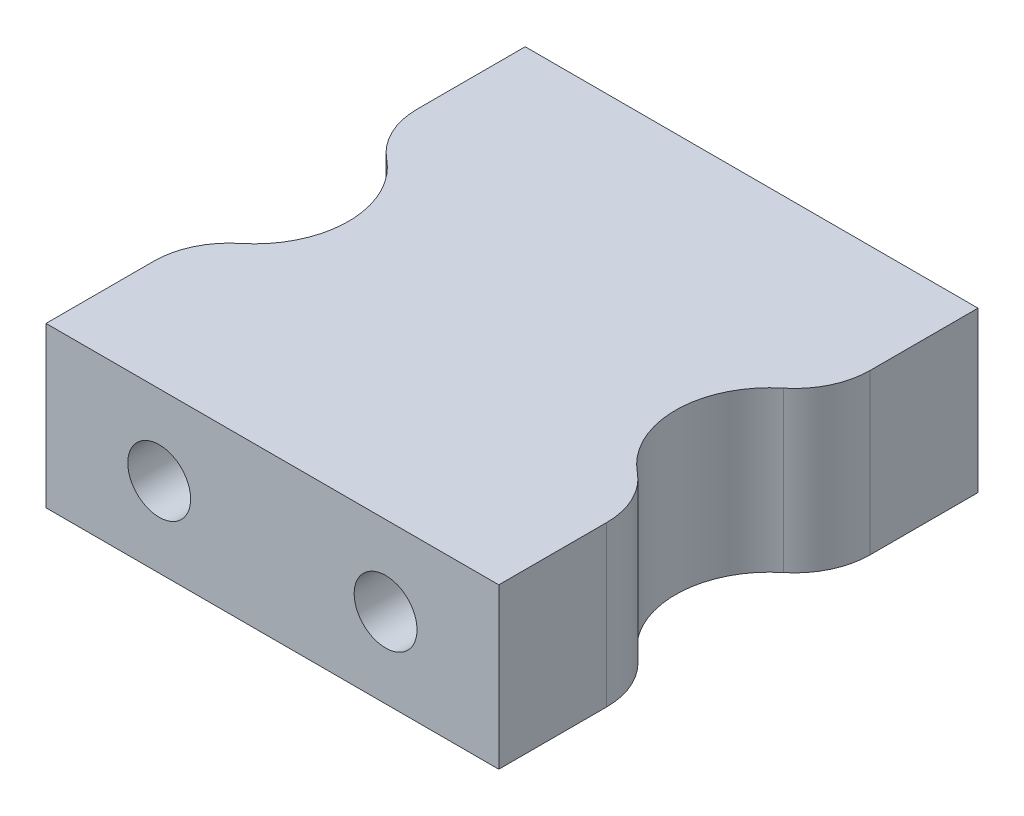
from build123d import *

# Parameters (mm, degrees)
SKETCH1_W           = 18
SKETCH1_H           = 6.35
BOSS_EXTRUDE1_DEPTH = 19.05
CUT_EXTRUDE1_DEPTH  = 7.35
SKETCH3_R           = 1.25
CUT_EXTRUDE2_DEPTH  = 5
FILLET2_R           = 3


with BuildPart() as part:
    # Sketch1 → Boss-Extrude1 (new body)
    with BuildSketch(Plane.XY):
        with Locations((9, 3.175)):
            Rectangle(SKETCH1_W, SKETCH1_H)
    extrude(amount=BOSS_EXTRUDE1_DEPTH)

    # Sketch2 → Cut-Extrude1 (cut, through all)
    with BuildSketch(Plane(origin=(0, 6.35, 0), x_dir=(1, 0, 0), z_dir=(0, 1, 0))):
        with BuildLine():
            Line((18, -6), (18, -13.05))
            ThreePointArc((18, -13.05), (15.5, -9.525), (18, -6))
        make_face()
        with BuildLine():
            Line((0, -6), (0, -13.05))
            ThreePointArc((0, -13.05), (2.5, -9.525), (0, -6))
        make_face()
    extrude(amount=-CUT_EXTRUDE1_DEPTH, mode=Mode.SUBTRACT)

    # Sketch3 → Cut-Extrude2 (cut)
    with BuildSketch(Plane(origin=(0, 0, 0), x_dir=(-1, 0, 0), z_dir=(0, 0, -1))):
        with Locations((-13.5, 3.175)):
            Circle(SKETCH3_R)
        with Locations((-4.5, 3.175)):
            Circle(SKETCH3_R)
    cut_extrude2 = extrude(amount=-CUT_EXTRUDE2_DEPTH, mode=Mode.SUBTRACT)

    # Mirror1: Cut-Extrude2 across plane
    add(cut_extrude2.mirror(Plane(origin=(0, 0, 9.525), x_dir=(1, 0, 0), z_dir=(0, 0, -1))), mode=Mode.SUBTRACT)

    # Fillet2
    fillet2_edges = [part.edges().sort_by_distance(p)[0] for p in [
        (18, 3.175, 13.05),
        (18, 3.175, 6),
        (0, 3.175, 6),
        (0, 3.175, 13.05),
    ]]
    fillet(fillet2_edges, radius=FILLET2_R)


solid = part.part
